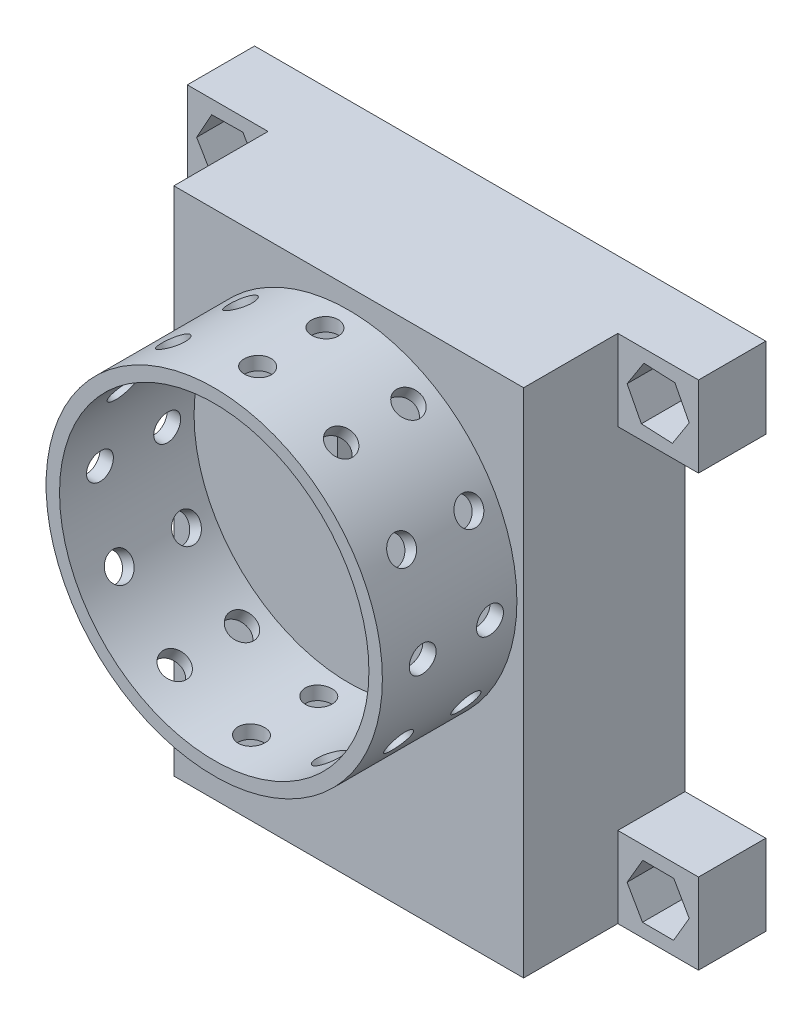
from build123d import *

# Parameters (mm, degrees)
SKETCH_1_W                          = 26
SKETCH_1_H                          = 38
EXTRUDE_1_DEPTH                     = 12
SKETCH_2_W                          = 22
SKETCH_2_H                          = 34
CUT_EXTRUDE_1_DEPTH                 = 10
SKETCH_3_W                          = 2
SKETCH_3_H                          = 7
CUT_EXTRUDE_3_DEPTH                 = 12
SKETCH_4_W                          = 6
SKETCH_4_H                          = 6
EXTRUDE_2_DEPTH                     = 5
SKETCH_5_R                          = 1
CUT_EXTRUDE_4_DEPTH                 = 13
CUT_EXTRUDE_START                   = 1
CUT_EXTRUDE_5_DEPTH                 = 4
SKETCH_7_R                          = 12.5
SKETCH_7_R_2                        = 11.5
EXTRUDE_3_DEPTH                     = 10
SKETCH_8_R                          = 1
CUT_EXTRUDE_6_DEPTH                 = 20
PATTERN_LINEAR_1_COUNT              = 2
PATTERN_LINEAR_1_PITCH              = 5
PATTERN_CIRCULAR_1_COUNT            = 12
PATTERN_CIRCULAR_1_COPY_1_SKETCH_R  = 1
PATTERN_CIRCULAR_1_COPY_1_DEPTH     = 20
PATTERN_CIRCULAR_1_COPY_2_SKETCH_R  = 1
PATTERN_CIRCULAR_1_COPY_2_DEPTH     = 20
PATTERN_CIRCULAR_1_COPY_3_SKETCH_R  = 1
PATTERN_CIRCULAR_1_COPY_3_DEPTH     = 20
PATTERN_CIRCULAR_1_COPY_4_SKETCH_R  = 1
PATTERN_CIRCULAR_1_COPY_4_DEPTH     = 20
PATTERN_CIRCULAR_1_COPY_5_SKETCH_R  = 1
PATTERN_CIRCULAR_1_COPY_5_DEPTH     = 20
PATTERN_CIRCULAR_1_COPY_6_SKETCH_R  = 1
PATTERN_CIRCULAR_1_COPY_6_DEPTH     = 20
PATTERN_CIRCULAR_1_COPY_7_SKETCH_R  = 1
PATTERN_CIRCULAR_1_COPY_7_DEPTH     = 20
PATTERN_CIRCULAR_1_COPY_8_SKETCH_R  = 1
PATTERN_CIRCULAR_1_COPY_8_DEPTH     = 20
PATTERN_CIRCULAR_1_COPY_9_SKETCH_R  = 1
PATTERN_CIRCULAR_1_COPY_9_DEPTH     = 20
PATTERN_CIRCULAR_1_COPY_10_SKETCH_R = 1
PATTERN_CIRCULAR_1_COPY_10_DEPTH    = 20
PATTERN_CIRCULAR_1_COPY_11_SKETCH_R = 1
PATTERN_CIRCULAR_1_COPY_11_DEPTH    = 20


with BuildPart() as part:
    # ｽｹｯﾁ1 → ﾎﾞｽ - 押し出し1 (new body)
    with BuildSketch(Plane.XY):
        Rectangle(SKETCH_1_W, SKETCH_1_H)
    extrude(amount=EXTRUDE_1_DEPTH)

    # ｽｹｯﾁ2 → ｶｯﾄ - 押し出し1 (cut)
    with BuildSketch(Plane.XY):
        Rectangle(SKETCH_2_W, SKETCH_2_H)
    extrude(amount=CUT_EXTRUDE_1_DEPTH, mode=Mode.SUBTRACT)

    # ｽｹｯﾁ3 → ｶｯﾄ - 押し出し3 (cut)
    with BuildSketch(Plane.XY):
        with Locations((0.147807357, 5.5)):
            Rectangle(SKETCH_3_W, SKETCH_3_H)
    extrude(amount=CUT_EXTRUDE_3_DEPTH, mode=Mode.SUBTRACT)

    # ｽｹｯﾁ4 → ﾎﾞｽ - 押し出し2 (add)
    with BuildSketch(Plane.XY):
        with Locations((16, 16)):
            Rectangle(SKETCH_4_W, SKETCH_4_H)
        with Locations((16, -16)):
            Rectangle(SKETCH_4_W, SKETCH_4_H)
        with Locations((-16, -16)):
            Rectangle(SKETCH_4_W, SKETCH_4_H)
        with Locations((-16, 16)):
            Rectangle(SKETCH_4_W, SKETCH_4_H)
    extrude(amount=EXTRUDE_2_DEPTH)

    # ｽｹｯﾁ5 → ｶｯﾄ - 押し出し4 (cut, through all)
    with BuildSketch(Plane.XY):
        with Locations((-16, 16)):
            Circle(SKETCH_5_R)
        with Locations((-16, -16)):
            Circle(SKETCH_5_R)
        with Locations((16, -16)):
            Circle(SKETCH_5_R)
        with Locations((16, 16)):
            Circle(SKETCH_5_R)
    extrude(amount=CUT_EXTRUDE_4_DEPTH, mode=Mode.SUBTRACT)

    # ｽｹｯﾁ6 → ｶｯﾄ - 押し出し5 (cut)
    with BuildSketch(Plane.XY.offset(CUT_EXTRUDE_START)):
        Polygon((-17.184124892, 17.98272075), (-18.309148984, 15.965878137), (-17.125024092, 13.983157387), (-14.815875108, 14.01727925), (-13.690851016, 16.034121863), (-14.874975908, 18.016842613), align=None)
        Polygon((-17.07560545, -13.956374239), (-18.307634549, -15.909688764), (-17.2320291, -17.953314524), (-14.92439455, -18.043625761), (-13.692365451, -16.090311236), (-14.7679709, -14.046685476), align=None)
        Polygon((14.939341307, 18.051423035), (13.693086191, 16.107154145), (14.753744884, 14.055731109), (17.060658693, 13.948576965), (18.306913809, 15.892845855), (17.246255116, 17.944268891), align=None)
        Polygon((14.854466591, -13.994735294), (13.690623119, -15.98942868), (14.836156527, -17.994693386), (17.145533409, -18.005264706), (18.309376881, -16.01057132), (17.163843473, -14.005306614), align=None)
    extrude(amount=CUT_EXTRUDE_5_DEPTH, mode=Mode.SUBTRACT)

    # ｽｹｯﾁ7 → ﾎﾞｽ - 押し出し3 (add)
    with BuildSketch(Plane.XY.offset(12)):
        with Locations((0, 5)):
            Circle(SKETCH_7_R)
        with Locations((0, 5)):
            Circle(SKETCH_7_R_2, mode=Mode.SUBTRACT)
    extrude(amount=EXTRUDE_3_DEPTH)

    # ｽｹｯﾁ8 → ｶｯﾄ - 押し出し6 (cut)
    with BuildSketch(Plane(origin=(0, 0, 0), x_dir=(0, 0, -1), z_dir=(1, 0, 0))):
        with Locations((-19, 5.226634502)):
            Circle(SKETCH_8_R)
    cut_extrude_6 = extrude(amount=-CUT_EXTRUDE_6_DEPTH, mode=Mode.SUBTRACT)

    # 直線ﾊﾟﾀｰﾝ1: ｶｯﾄ - 押し出し6 ×2
    with Locations(*[(0, 0, -i * PATTERN_LINEAR_1_PITCH) for i in range(1, PATTERN_LINEAR_1_COUNT)]):
        add(cut_extrude_6, mode=Mode.SUBTRACT)

    # 円形ﾊﾟﾀｰﾝ1: ｶｯﾄ - 押し出し6 ×12 about axis
    pattern_circular_1_axis = Axis((0, 5, 22), (0, 0, -1))
    for i in range(1, PATTERN_CIRCULAR_1_COUNT):
        add(cut_extrude_6.rotate(pattern_circular_1_axis, i * 360 / PATTERN_CIRCULAR_1_COUNT), mode=Mode.SUBTRACT)

    # 円形ﾊﾟﾀｰﾝ1 copy 1 sketch → 円形ﾊﾟﾀｰﾝ1 copy 1 (cut)
    with BuildSketch(Plane(origin=(-2.5, 0.669872981, -5), x_dir=(0, 0, -1), z_dir=(0.866025404, -0.5, 0))):
        with Locations((-19, 5.226634502)):
            Circle(PATTERN_CIRCULAR_1_COPY_1_SKETCH_R)
    extrude(amount=-PATTERN_CIRCULAR_1_COPY_1_DEPTH, mode=Mode.SUBTRACT)

    # 円形ﾊﾟﾀｰﾝ1 copy 2 sketch → 円形ﾊﾟﾀｰﾝ1 copy 2 (cut)
    with BuildSketch(Plane(origin=(-4.330127019, 2.5, -5), x_dir=(0, 0, -1), z_dir=(0.5, -0.866025404, 0))):
        with Locations((-19, 5.226634502)):
            Circle(PATTERN_CIRCULAR_1_COPY_2_SKETCH_R)
    extrude(amount=-PATTERN_CIRCULAR_1_COPY_2_DEPTH, mode=Mode.SUBTRACT)

    # 円形ﾊﾟﾀｰﾝ1 copy 3 sketch → 円形ﾊﾟﾀｰﾝ1 copy 3 (cut)
    with BuildSketch(Plane(origin=(-5, 5, -5), x_dir=(0, 0, -1), z_dir=(0, -1, 0))):
        with Locations((-19, 5.226634502)):
            Circle(PATTERN_CIRCULAR_1_COPY_3_SKETCH_R)
    extrude(amount=-PATTERN_CIRCULAR_1_COPY_3_DEPTH, mode=Mode.SUBTRACT)

    # 円形ﾊﾟﾀｰﾝ1 copy 4 sketch → 円形ﾊﾟﾀｰﾝ1 copy 4 (cut)
    with BuildSketch(Plane(origin=(-4.330127019, 7.5, -5), x_dir=(0, 0, -1), z_dir=(-0.5, -0.866025404, 0))):
        with Locations((-19, 5.226634502)):
            Circle(PATTERN_CIRCULAR_1_COPY_4_SKETCH_R)
    extrude(amount=-PATTERN_CIRCULAR_1_COPY_4_DEPTH, mode=Mode.SUBTRACT)

    # 円形ﾊﾟﾀｰﾝ1 copy 5 sketch → 円形ﾊﾟﾀｰﾝ1 copy 5 (cut)
    with BuildSketch(Plane(origin=(-2.5, 9.330127019, -5), x_dir=(0, 0, -1), z_dir=(-0.866025404, -0.5, 0))):
        with Locations((-19, 5.226634502)):
            Circle(PATTERN_CIRCULAR_1_COPY_5_SKETCH_R)
    extrude(amount=-PATTERN_CIRCULAR_1_COPY_5_DEPTH, mode=Mode.SUBTRACT)

    # 円形ﾊﾟﾀｰﾝ1 copy 6 sketch → 円形ﾊﾟﾀｰﾝ1 copy 6 (cut)
    with BuildSketch(Plane(origin=(0, 10, -5), x_dir=(0, 0, -1), z_dir=(-1, 0, 0))):
        with Locations((-19, 5.226634502)):
            Circle(PATTERN_CIRCULAR_1_COPY_6_SKETCH_R)
    extrude(amount=-PATTERN_CIRCULAR_1_COPY_6_DEPTH, mode=Mode.SUBTRACT)

    # 円形ﾊﾟﾀｰﾝ1 copy 7 sketch → 円形ﾊﾟﾀｰﾝ1 copy 7 (cut)
    with BuildSketch(Plane(origin=(2.5, 9.330127019, -5), x_dir=(0, 0, -1), z_dir=(-0.866025404, 0.5, 0))):
        with Locations((-19, 5.226634502)):
            Circle(PATTERN_CIRCULAR_1_COPY_7_SKETCH_R)
    extrude(amount=-PATTERN_CIRCULAR_1_COPY_7_DEPTH, mode=Mode.SUBTRACT)

    # 円形ﾊﾟﾀｰﾝ1 copy 8 sketch → 円形ﾊﾟﾀｰﾝ1 copy 8 (cut)
    with BuildSketch(Plane(origin=(4.330127019, 7.5, -5), x_dir=(0, 0, -1), z_dir=(-0.5, 0.866025404, 0))):
        with Locations((-19, 5.226634502)):
            Circle(PATTERN_CIRCULAR_1_COPY_8_SKETCH_R)
    extrude(amount=-PATTERN_CIRCULAR_1_COPY_8_DEPTH, mode=Mode.SUBTRACT)

    # 円形ﾊﾟﾀｰﾝ1 copy 9 sketch → 円形ﾊﾟﾀｰﾝ1 copy 9 (cut)
    with BuildSketch(Plane(origin=(5, 5, -5), x_dir=(0, 0, -1), z_dir=(0, 1, 0))):
        with Locations((-19, 5.226634502)):
            Circle(PATTERN_CIRCULAR_1_COPY_9_SKETCH_R)
    extrude(amount=-PATTERN_CIRCULAR_1_COPY_9_DEPTH, mode=Mode.SUBTRACT)

    # 円形ﾊﾟﾀｰﾝ1 copy 10 sketch → 円形ﾊﾟﾀｰﾝ1 copy 10 (cut)
    with BuildSketch(Plane(origin=(4.330127019, 2.5, -5), x_dir=(0, 0, -1), z_dir=(0.5, 0.866025404, 0))):
        with Locations((-19, 5.226634502)):
            Circle(PATTERN_CIRCULAR_1_COPY_10_SKETCH_R)
    extrude(amount=-PATTERN_CIRCULAR_1_COPY_10_DEPTH, mode=Mode.SUBTRACT)

    # 円形ﾊﾟﾀｰﾝ1 copy 11 sketch → 円形ﾊﾟﾀｰﾝ1 copy 11 (cut)
    with BuildSketch(Plane(origin=(2.5, 0.669872981, -5), x_dir=(0, 0, -1), z_dir=(0.866025404, 0.5, 0))):
        with Locations((-19, 5.226634502)):
            Circle(PATTERN_CIRCULAR_1_COPY_11_SKETCH_R)
    extrude(amount=-PATTERN_CIRCULAR_1_COPY_11_DEPTH, mode=Mode.SUBTRACT)


solid = part.part
